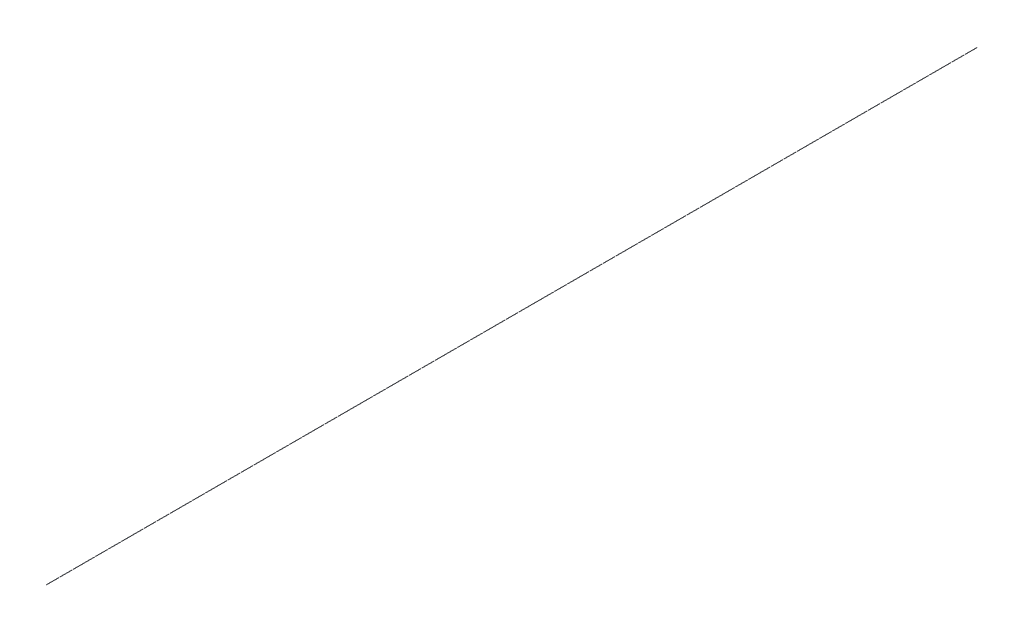
from build123d import *

# Parameters (mm, degrees)
SKETCH1_R           = 5
BOSS_EXTRUDE1_DEPTH = 55000


with BuildPart() as part:
    # Sketch1 → Boss-Extrude1 (new body)
    with BuildSketch(Plane.XY):
        Circle(SKETCH1_R)
    extrude(amount=BOSS_EXTRUDE1_DEPTH)


solid = part.part
